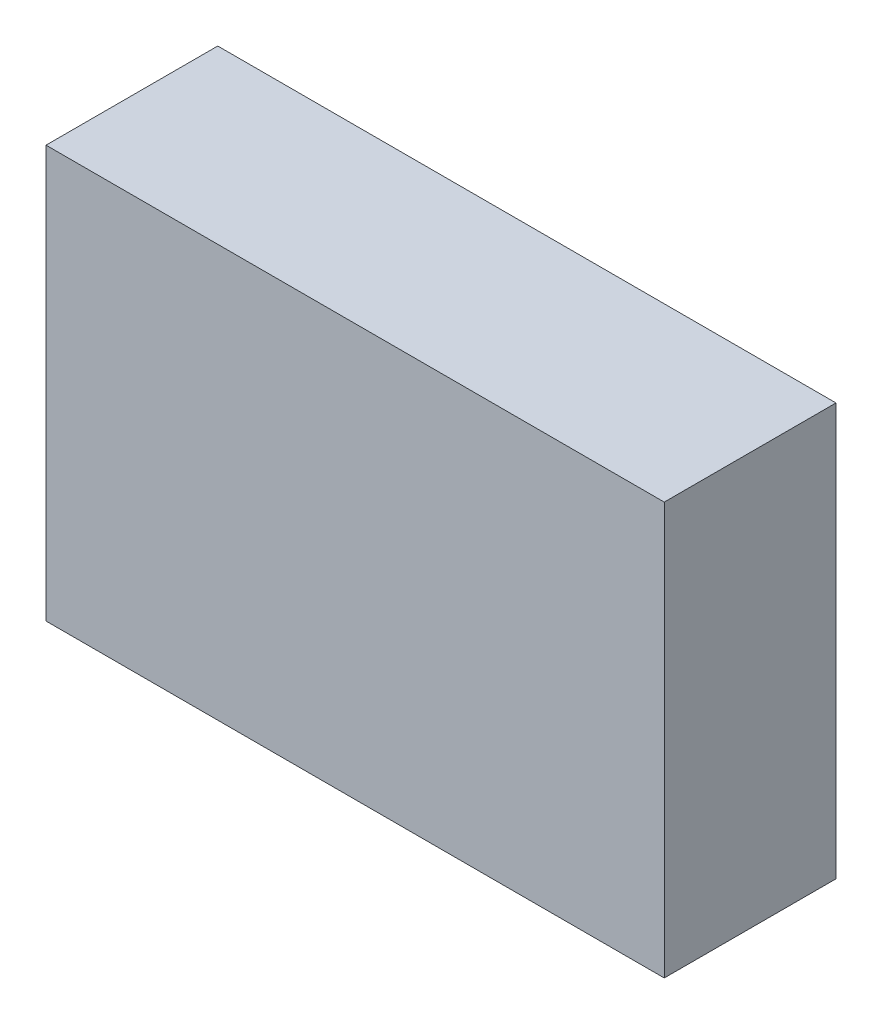
from build123d import *

# Parameters (mm, degrees)
SKETCH1_W           = 90
SKETCH1_H           = 60
BOSS_EXTRUDE1_DEPTH = 25


with BuildPart() as part:
    # Sketch1 → Boss-Extrude1 (new body)
    with BuildSketch(Plane.XY):
        with Locations((45, 30)):
            Rectangle(SKETCH1_W, SKETCH1_H)
    extrude(amount=BOSS_EXTRUDE1_DEPTH)


solid = part.part
